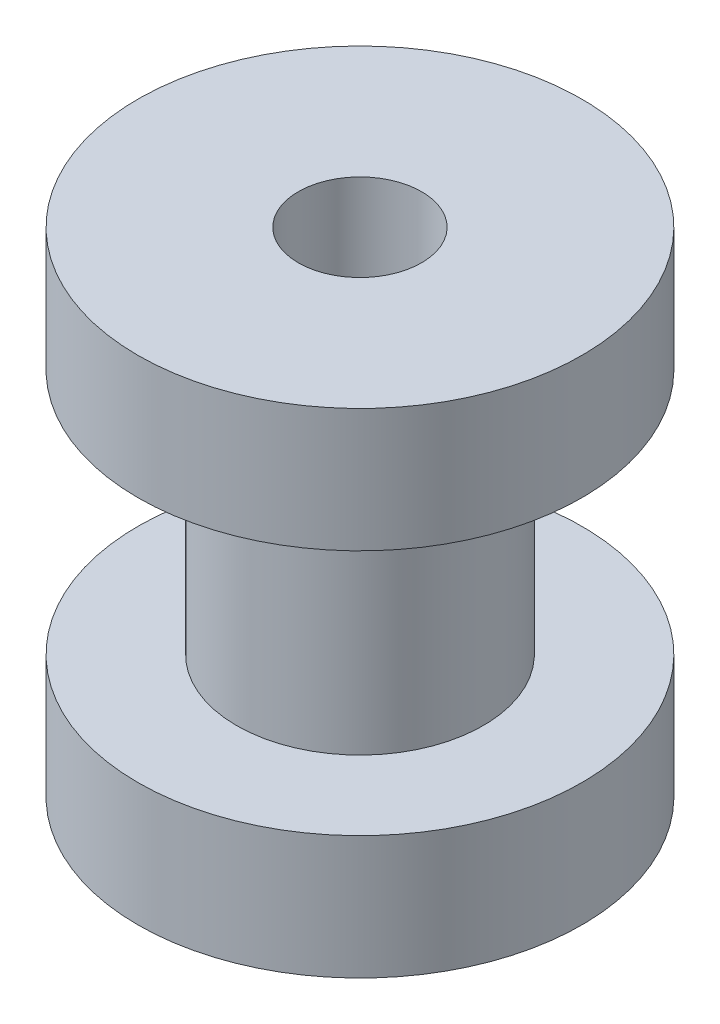
from build123d import *

# Parameters (mm, degrees)
SKETCH1_R               = 5
BOSS_EXTRUDE1_DEPTH     = 5
SKETCH3_R               = 9
BOSS_EXTRUDE2_DEPTH     = 5
SKETCH2_R               = 2.5
CUT_EXTRUDE1_DEPTH      = 7
CUT_EXTRUDE1_DEPTH_BACK = 15


with BuildPart() as part:
    # Sketch1 → Boss-Extrude1 (new body)
    with BuildSketch(Plane(origin=(0, 0, 0), x_dir=(1, 0, 0), z_dir=(0, 1, 0))):
        Circle(SKETCH1_R)
    boss_extrude1 = extrude(amount=BOSS_EXTRUDE1_DEPTH)

    # Sketch3 → Boss-Extrude2 (add)
    with BuildSketch(Plane(origin=(0, 5, 0), x_dir=(1, 0, 0), z_dir=(0, 1, 0))):
        Circle(SKETCH3_R)
    boss_extrude2 = extrude(amount=BOSS_EXTRUDE2_DEPTH)

    # Mirror1: Boss-Extrude1, Boss-Extrude2 across plane
    add(boss_extrude1.mirror(Plane.ZX))
    add(boss_extrude2.mirror(Plane.ZX))

    # Sketch2 → Cut-Extrude1 (cut, two sides)
    with BuildSketch(Plane(origin=(0, 4, 0), x_dir=(1, 0, 0), z_dir=(0, 1, 0))) as cut_extrude1_sk:
        Circle(SKETCH2_R)
    extrude(amount=CUT_EXTRUDE1_DEPTH, mode=Mode.SUBTRACT)
    extrude(cut_extrude1_sk.sketch, amount=-CUT_EXTRUDE1_DEPTH_BACK, mode=Mode.SUBTRACT)


solid = part.part
